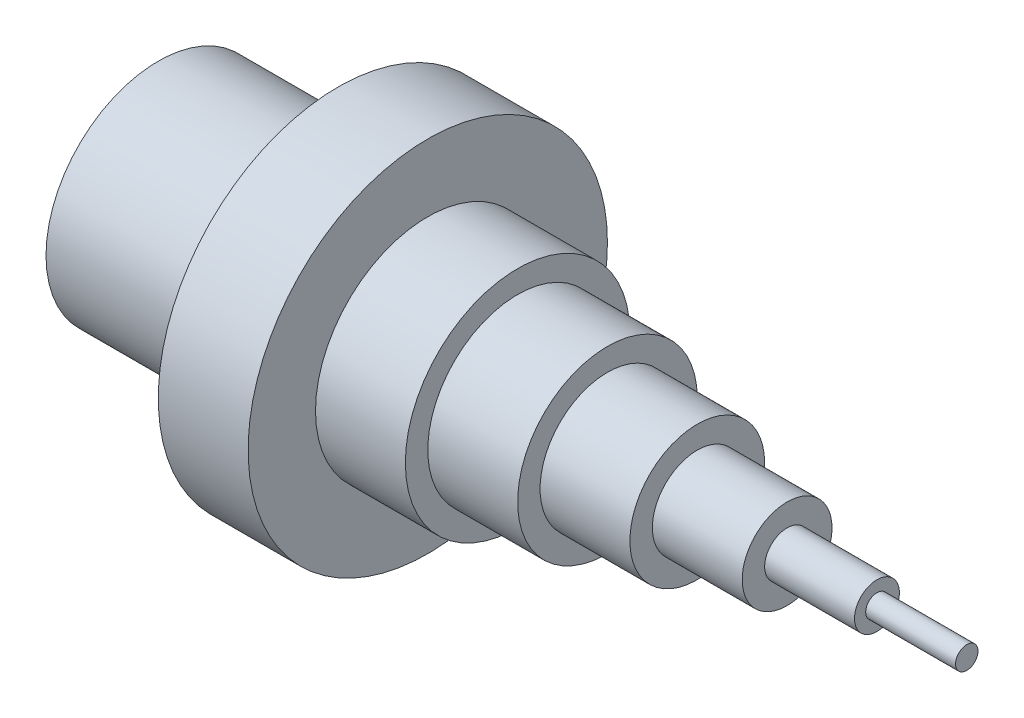
from build123d import *


with BuildPart() as part:
    # Sketch1 → Revolve4 (revolve)
    with BuildSketch(Plane.XY, mode=Mode.PRIVATE) as revolve4_sk:
        Polygon((-180, 0), (0, 0), (0, 2.5), (-20, 2.5), (-20, 5), (-40, 5), (-40, 10), (-60, 10), (-60, 15), (-80, 15), (-80, 20), (-100, 20), (-100, 25), (-120, 25), (-120, 40), (-140, 40), (-140, 25), (-180, 25), align=None)
    revolve(revolve4_sk.sketch.rotate(Axis((0, 0, 0), (-1, 0, 0)), 90), axis=Axis((0, 0, 0), (-1, 0, 0)))  # turned: the seam where the file's is


solid = part.part
